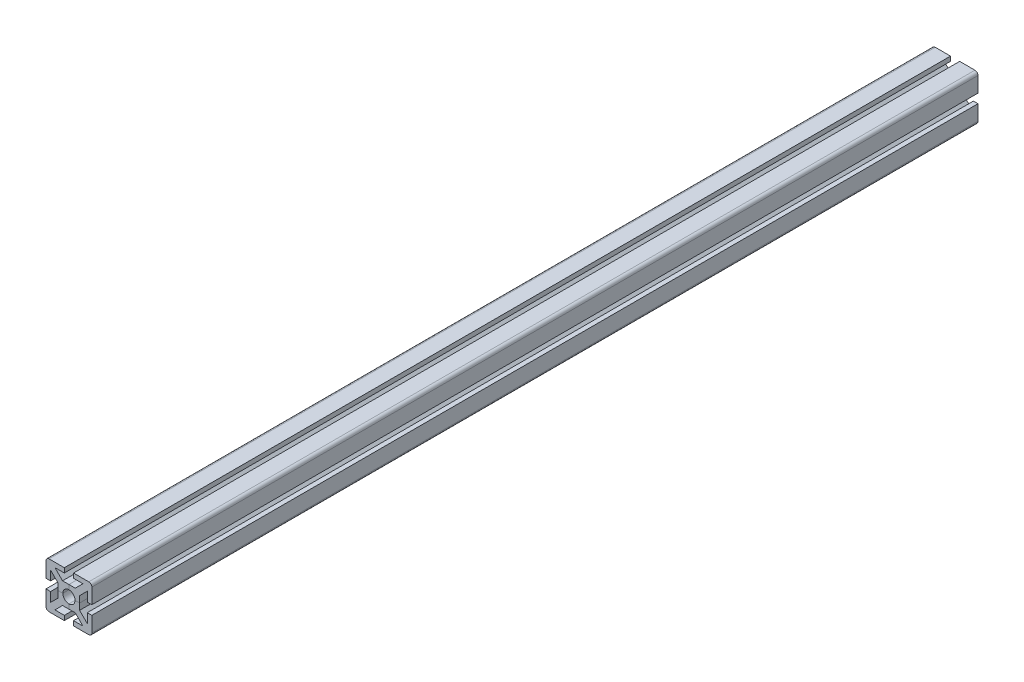
from build123d import *

# Parameters (mm, degrees)
SALIENTE_EXTRUIR1_DEPTH = 290
REDONDEO1_R             = 2
MATRIZC4_COUNT          = 4


with BuildPart() as part:
    # Croquis1 → Saliente-Extruir1 (new body, symmetric)
    with BuildSketch(Plane.XY):
        with BuildLine():
            Line((0, 4), (0, 7))
            Line((0, 7), (4.171572875, 7))
            Line((4.171572875, 7), (9.171572875, 12))
            Line((9.171572875, 12), (3, 12))
            Line((3, 12), (3, 15))
            Line((3, 15), (15, 15))
            Line((15, 15), (2.828427125, 2.828427125))
            ThreePointArc((2.828427125, 2.828427125), (1.530733729, 3.69551813), (0, 4))
        make_face()
    saliente_extruir1 = extrude(amount=SALIENTE_EXTRUIR1_DEPTH, both=True)

    # Simetría1: Saliente-Extruir1 across plane
    add(saliente_extruir1.mirror(Plane(origin=(2.828427125, 2.828427125, 290), x_dir=(0, 0, 1), z_dir=(-0.707106781, 0.707106781, 0))))

    # Redondeo1
    redondeo1_edges = [part.edges().sort_by_distance(p)[0] for p in [
        (15, 15, 0),
    ]]
    fillet(redondeo1_edges, radius=REDONDEO1_R)


with BuildPart() as matrizc4_1:
    # MatrizC4: pattern copy
    add(part.part.rotate(Axis((0, 0, 0), (0, 0, 1)), 1 * 360 / MATRIZC4_COUNT))


with BuildPart() as matrizc4_2:
    # MatrizC4: pattern copy
    add(part.part.rotate(Axis((0, 0, 0), (0, 0, 1)), 2 * 360 / MATRIZC4_COUNT))


with BuildPart() as matrizc4_3:
    # MatrizC4: pattern copy
    add(part.part.rotate(Axis((0, 0, 0), (0, 0, 1)), 3 * 360 / MATRIZC4_COUNT))


solid = Compound([part.part, matrizc4_1.part, matrizc4_2.part, matrizc4_3.part])
